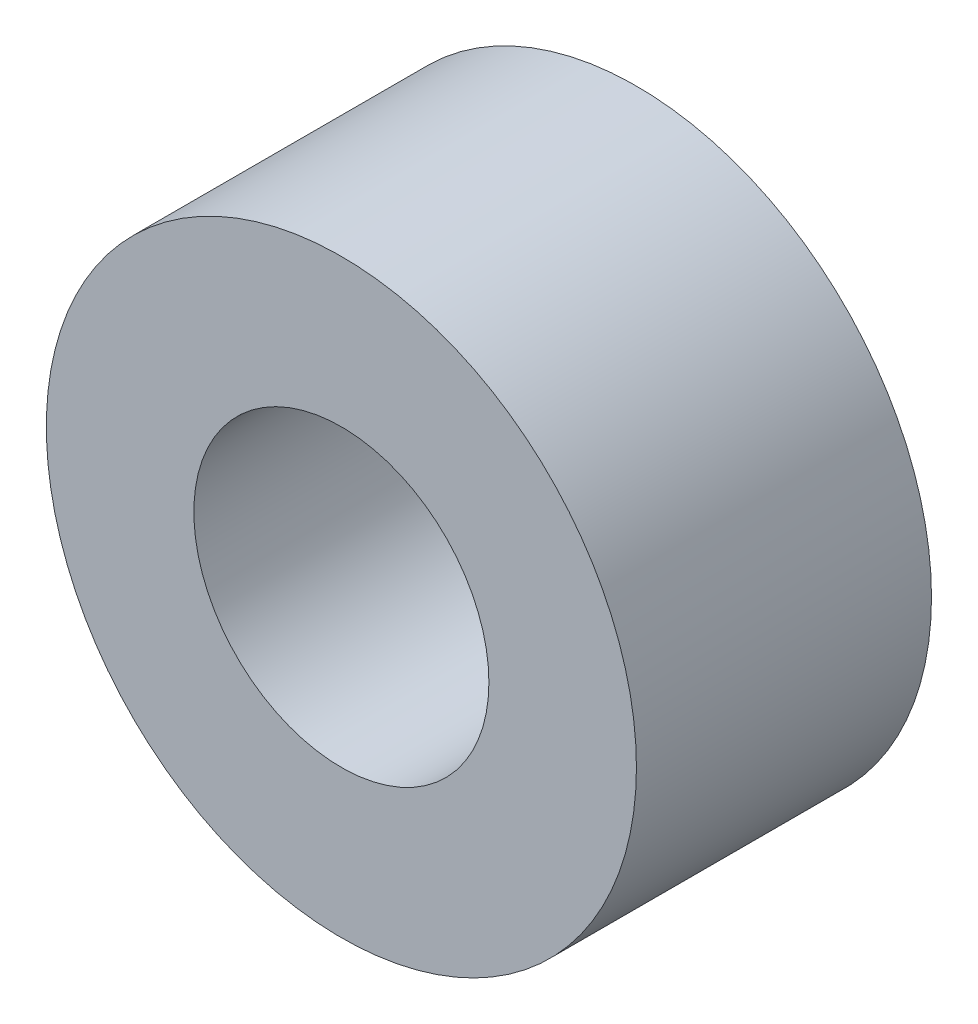
from build123d import *

# Parameters (mm, degrees)
SKETCH1_R                 = 5
BOSS_EXTRUDE1_DEPTH       = 5
F_5_0MM_DOWEL_HOLE1_D     = 5
F_5_0MM_DOWEL_HOLE1_DEPTH = 5


with BuildPart() as part:
    # Sketch1 → Boss-Extrude1 (new body)
    with BuildSketch(Plane.XY):
        Circle(SKETCH1_R)
    extrude(amount=BOSS_EXTRUDE1_DEPTH)

    # Ø5.0mm Dowel Hole1
    with Locations(Plane.XY.offset(5)):
        with Locations((0, 0)):
            Hole(F_5_0MM_DOWEL_HOLE1_D / 2, depth=F_5_0MM_DOWEL_HOLE1_DEPTH)


solid = part.part
